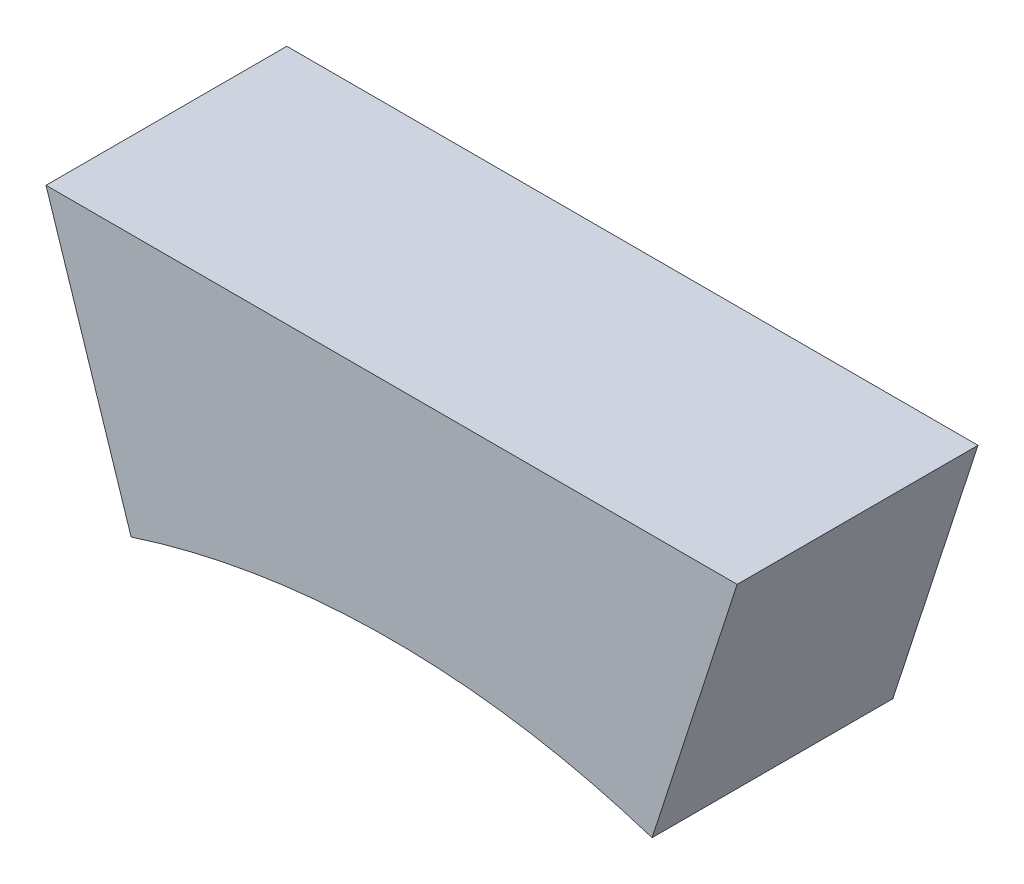
from build123d import *

# Parameters (mm, degrees)
EXTRUDE_1_DEPTH = 480
SCALE_1_SCALE   = 1.3


with BuildPart() as part:
    # 草图1 → 凸台-拉伸1 (new body)
    with BuildSketch(Plane.XY):
        with BuildLine():
            Line((-6833.3126292, 5666.028511287), (-6759.14855055, 5437.774947376))
            ThreePointArc((-6759.14855055, 5437.774947376), (-6502.809901268, 5499.3164122), (-6240, 5520))
            Line((-6240, 5520), (-6240, 5760))
            ThreePointArc((-6240, 5760), (-6540.354172877, 5736.361613943), (-6833.3126292, 5666.028511287))
        make_face()
        with BuildLine():
            ThreePointArc((-6240, 5520), (-5977.190098732, 5499.3164122), (-5720.85144945, 5437.774947376))
            Line((-5720.85144945, 5437.774947376), (-5683.769410125, 5551.901729331))
            Line((-5683.769410125, 5551.901729331), (-5646.6873708, 5666.028511287))
            ThreePointArc((-5646.6873708, 5666.028511287), (-5939.645827123, 5736.361613943), (-6240, 5760))
            Line((-6240, 5760), (-6240, 5520))
        make_face()
        with BuildLine():
            ThreePointArc((-6240, 5760), (-5939.645827123, 5736.361613943), (-5646.6873708, 5666.028511287))
            Line((-5646.6873708, 5666.028511287), (-5551.170243986, 5960))
            Line((-5551.170243986, 5960), (-6928.829756014, 5960))
            Line((-6928.829756014, 5960), (-6833.3126292, 5666.028511287))
            ThreePointArc((-6833.3126292, 5666.028511287), (-6540.354172877, 5736.361613943), (-6240, 5760))
        make_face()
    extrude(amount=EXTRUDE_1_DEPTH)


with BuildPart() as part_1:
    # 缩放比例1: scaled about (0, 0, 0)
    add(part.part.scale(SCALE_1_SCALE))


solid = part_1.part
